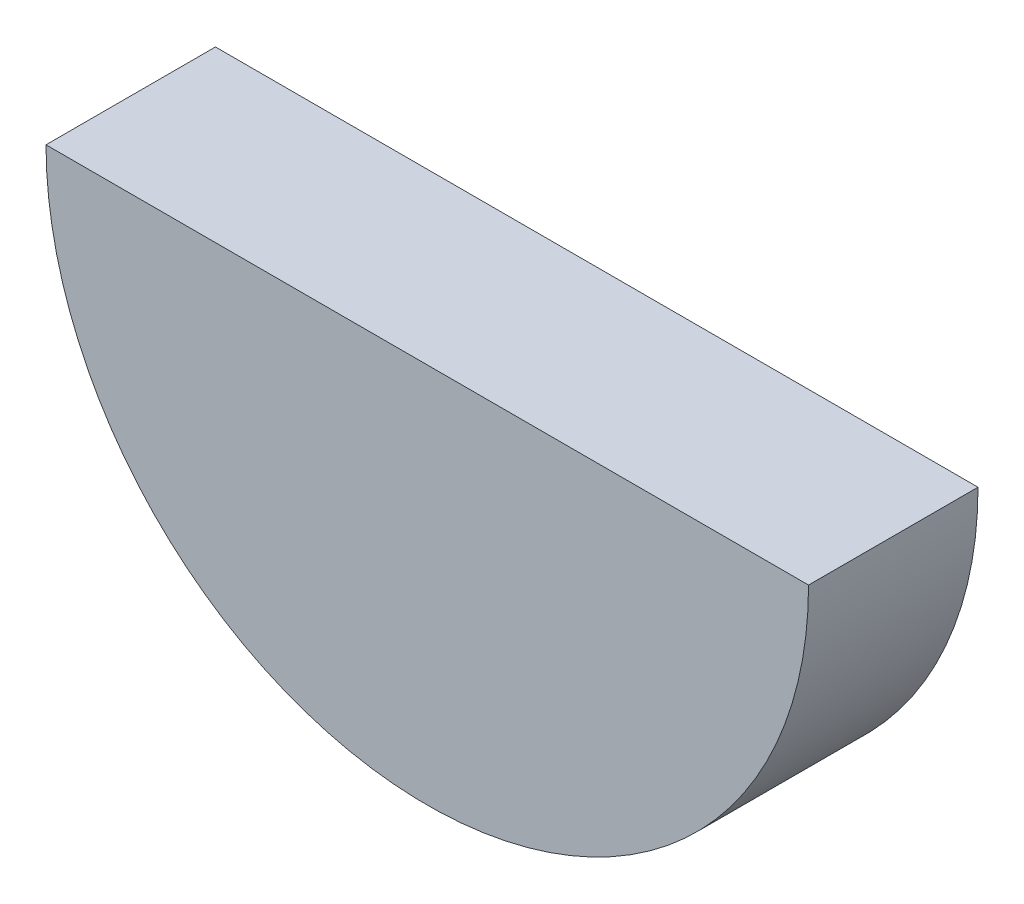
from build123d import *

# Parameters (mm, degrees)
BOSS_EXTRUDE1_DEPTH = 25.4


with BuildPart() as part:
    # Sketch4 → Boss-Extrude1 (new body)
    with BuildSketch(Plane.XY):
        with BuildLine():
            Line((-57.15, 0), (57.15, 0))
            ThreePointArc((57.15, 0), (0, -57.15), (-57.15, 0))
        make_face()
    extrude(amount=BOSS_EXTRUDE1_DEPTH)


solid = part.part
